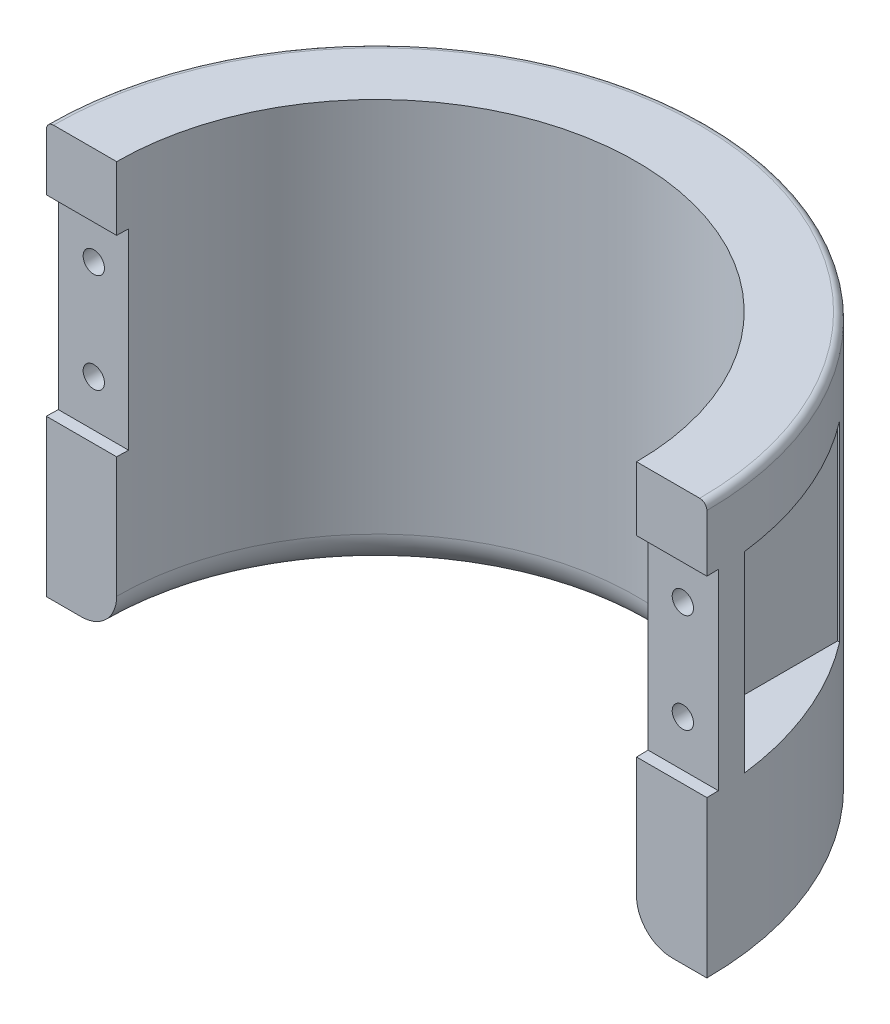
from build123d import *

# Parameters (mm, degrees)
EXTRUDE_1_DEPTH          = 58
FILLET_1_R               = 5
SKETCH_2_W               = 14.1984483
SKETCH_2_H               = 27
CUT_EXTRUDE_1_DEPTH      = 1.65
CUT_EXTRUDE_START        = -22.111141
SKETCH_3_R               = 1.5
CUT_EXTRUDE_2_DEPTH      = 22.111141
SKETCH_5_W               = 9.9
SKETCH_5_H               = 27
CUT_EXTRUDE_3_DEPTH      = 22.65
FILLET_2_R               = 1
EXTRUDE_2_DEPTH          = 10
SKETCH_9_R               = 1
CUT_EXTRUDE_4_DEPTH      = 2
PATTERN_CIRCULAR_1_COUNT = 5


with BuildPart() as part:
    # 草图1 → 凸台-拉伸1 (new body)
    with BuildSketch(Plane(origin=(0, 0, 0), x_dir=(1, 0, 0), z_dir=(0, 1, 0))):
        with BuildLine():
            Line((-46.5, 0), (-36.6, 0))
            ThreePointArc((-36.6, 0), (0, 36.6), (36.6, 0))
            Line((36.6, 0), (46.5, 0))
            ThreePointArc((46.5, 0), (0, 46.5), (-46.5, 0))
        make_face()
    extrude(amount=EXTRUDE_1_DEPTH)

    # 圆角1
    fillet_1_edges = [part.edges().sort_by_distance(p)[0] for p in [
        (0, 0, -36.6),
    ]]
    fillet(fillet_1_edges, radius=FILLET_1_R)

    # 草图2 → 切除-拉伸1 (cut)
    with BuildSketch(Plane.XY):
        with Locations((-41.149885232, 35.5)):
            Rectangle(SKETCH_2_W, SKETCH_2_H)
    cut_extrude_1 = extrude(amount=-CUT_EXTRUDE_1_DEPTH, mode=Mode.SUBTRACT)

    # 草图3 → 切除-拉伸2 (cut)
    with BuildSketch(Plane.XY.offset(-1.65).offset(CUT_EXTRUDE_START)):
        with Locations((-41.470716586, 28.5)):
            Circle(SKETCH_3_R)
        with Locations((-41.470716586, 42.5)):
            Circle(SKETCH_3_R)
    cut_extrude_2 = extrude(amount=CUT_EXTRUDE_2_DEPTH, mode=Mode.SUBTRACT)

    # 草图5 → 切除-拉伸3 (cut)
    with BuildSketch(Plane.XY.offset(-5.65)):
        with Locations((-41.55, 35.5)):
            Rectangle(SKETCH_5_W, SKETCH_5_H)
    cut_extrude_3 = extrude(amount=-CUT_EXTRUDE_3_DEPTH, mode=Mode.SUBTRACT)

    # 镜向2: 切除-拉伸1, 切除-拉伸2, 切除-拉伸3 across plane
    add(cut_extrude_1.mirror(Plane(origin=(0, 0, 0), x_dir=(0, 0, 1), z_dir=(1, 0, 0))), mode=Mode.SUBTRACT)
    add(cut_extrude_2.mirror(Plane(origin=(0, 0, 0), x_dir=(0, 0, 1), z_dir=(1, 0, 0))), mode=Mode.SUBTRACT)
    add(cut_extrude_3.mirror(Plane(origin=(0, 0, 0), x_dir=(0, 0, 1), z_dir=(1, 0, 0))), mode=Mode.SUBTRACT)

    # 圆角2
    fillet_2_edges = [part.edges().sort_by_distance(p)[0] for p in [
        (0, 58, -46.5),
    ]]
    fillet(fillet_2_edges, radius=FILLET_2_R)

    # 草图8 → 凸台-拉伸2 (add)
    with BuildSketch(Plane.XZ):
        with BuildLine():
            Line((0, -41.6), (0, -46.5))
            ThreePointArc((0, -46.5), (-2.433621965, -46.436273366), (-4.860573542, -46.245268135))
            Line((-4.860573542, -46.245268135), (-4.348384072, -41.372110847))
            ThreePointArc((-4.348384072, -41.372110847), (-2.17717578, -41.542988646), (0, -41.6))
        make_face()
    extrude(amount=-EXTRUDE_2_DEPTH)

    # 草图9 → 切除-拉伸4 (cut)
    with BuildSketch(Plane.XZ):
        with Locations((0, -44.5)):
            Circle(SKETCH_9_R)
    cut_extrude_4 = extrude(amount=-CUT_EXTRUDE_4_DEPTH, mode=Mode.SUBTRACT)

    # 阵列(圆周)1: 切除-拉伸4 ×5 about axis
    pattern_circular_1_axis = Axis((0, 0, 0), (0, 1, 0))
    for i in range(1, PATTERN_CIRCULAR_1_COUNT):
        add(cut_extrude_4.rotate(pattern_circular_1_axis, i * 360 / PATTERN_CIRCULAR_1_COUNT), mode=Mode.SUBTRACT)


solid = part.part
